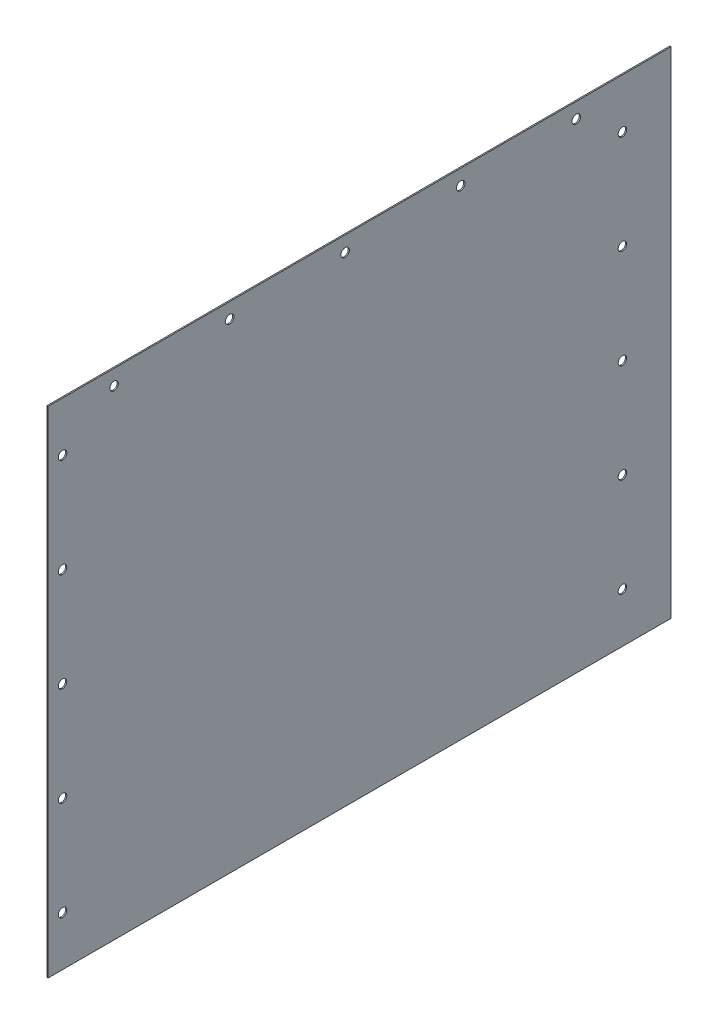
from build123d import *

# Parameters (mm, degrees)
SKETCH1_W                = 479.3996
SKETCH1_H                = 381
BOSS_EXTRUDE1_DEPTH      = 0.9144
F_0_257_DIAMETER_HOLE1_D = 6.5278
SKETCH4_R                = 3.2639
CUT_EXTRUDE1_DEPTH       = 2.54
SKETCH5_R                = 3.2639
CUT_EXTRUDE2_DEPTH       = 2.54


with BuildPart() as part:
    # Sketch1 → Boss-Extrude1 (new body)
    with BuildSketch(Plane(origin=(0, 0, 0), x_dir=(0, 0, -1), z_dir=(1, 0, 0))):
        Rectangle(SKETCH1_W, SKETCH1_H)
    extrude(amount=BOSS_EXTRUDE1_DEPTH)

    # F (0.257) Diameter Hole1 (through all)
    with Locations(Plane.ZY):
        with Locations((188.8998, 178.7144), (99.9998, 178.7144), (11.0998, 178.7144), (-77.8002, 178.7144), (-166.7002, 178.7144)):
            Hole(F_0_257_DIAMETER_HOLE1_D / 2)

    # Sketch4 → Cut-Extrude1 (cut)
    with BuildSketch(Plane(origin=(0.9144, 0, 0), x_dir=(0, 0, -1), z_dir=(1, 0, 0))):
        with Locations((-228.6, 152.4)):
            Circle(SKETCH4_R)
        with Locations((-228.6, 76.2)):
            Circle(SKETCH4_R)
        with Locations((-228.6, 0)):
            Circle(SKETCH4_R)
        with Locations((-228.6, -76.2)):
            Circle(SKETCH4_R)
        with Locations((-228.6, -152.4)):
            Circle(SKETCH4_R)
    extrude(amount=-CUT_EXTRUDE1_DEPTH, mode=Mode.SUBTRACT)

    # Sketch5 → Cut-Extrude2 (cut)
    with BuildSketch(Plane.ZY):
        with Locations((-202.2856, 152.4)):
            Circle(SKETCH5_R)
        with Locations((-202.2856, 76.2)):
            Circle(SKETCH5_R)
        with Locations((-202.2856, 0)):
            Circle(SKETCH5_R)
        with Locations((-202.2856, -76.2)):
            Circle(SKETCH5_R)
        with Locations((-202.2856, -152.4)):
            Circle(SKETCH5_R)
    extrude(amount=-CUT_EXTRUDE2_DEPTH, mode=Mode.SUBTRACT)


solid = part.part
